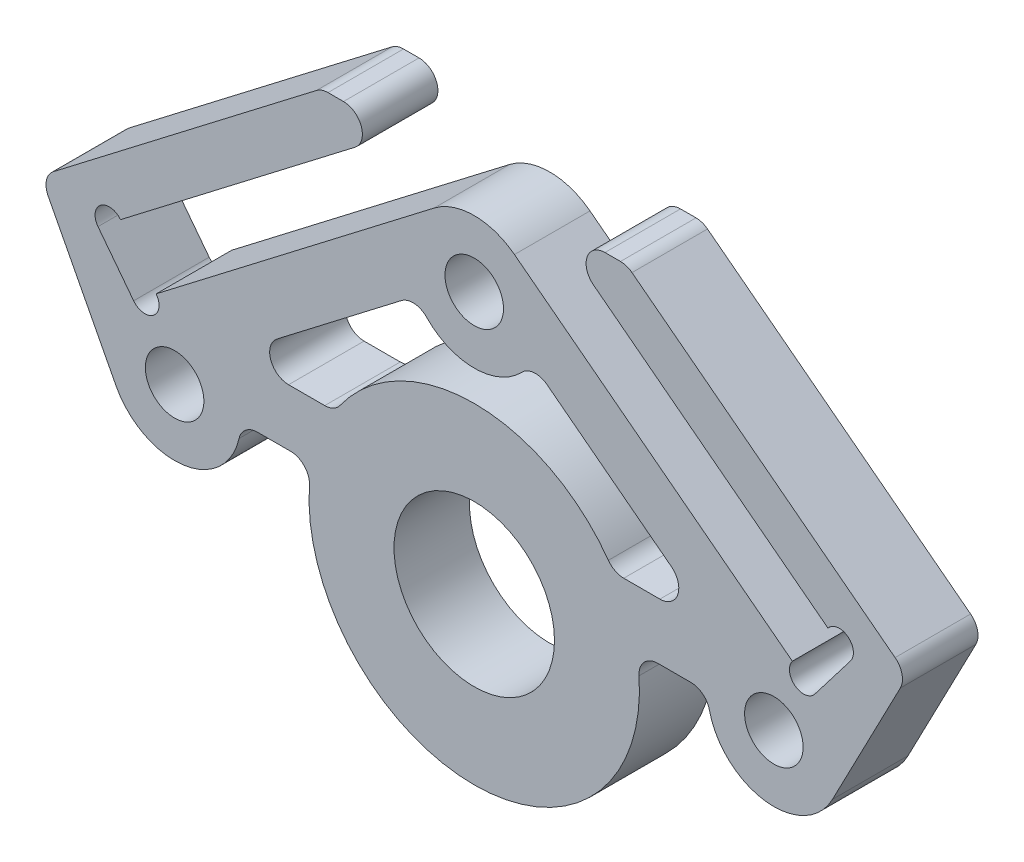
from build123d import *

# Parameters (mm, degrees)
SKETCH_1_R             = 4.25
SKETCH_1_R_2           = 1.55
EXTRUDE_1_DEPTH        = 2
FILLET_1_R             = 1
EXTRUDE_2_DEPTH        = 4
SKETCH_3_R             = 0.75
CUT_EXTRUDE_1_DEPTH    = 5
FILLET_2_R             = 1
FILLET_2_OF_MIRROR_1_R = 1
CUT_EXTRUDE_2_DEPTH    = 5
FILLET_3_R             = 1


with BuildPart() as part:
    # 草图1 → 凸台-拉伸1 (new body, symmetric)
    with BuildSketch(Plane.XY):
        with BuildLine():
            Line((-17.997731807, 4.466704665), (-2.130665002, 16.641933245))
            ThreePointArc((-2.130665002, 16.641933245), (0, 17.365196554), (2.130665002, 16.641933245))
            Line((2.130665002, 16.641933245), (17.997731807, 4.466704665))
            ThreePointArc((17.997731807, 4.466704665), (17.415077222, -1.449086621), (12.367066806, 1.689967974))
            Line((12.367066806, 1.689967974), (8.585249457, 1.689967974))
            ThreePointArc((8.585249457, 1.689967974), (0, -8.75), (-8.585249457, 1.689967974))
            Line((-8.585249457, 1.689967974), (-12.367066806, 1.689967974))
            ThreePointArc((-12.367066806, 1.689967974), (-17.415077222, -1.449086621), (-17.997731807, 4.466704665))
        make_face()
        Circle(SKETCH_1_R, mode=Mode.SUBTRACT)
        with Locations((-15.867066806, 1.689967974)):
            Circle(SKETCH_1_R_2, mode=Mode.SUBTRACT)
        with Locations((0, 13.865196554)):
            Circle(SKETCH_1_R_2, mode=Mode.SUBTRACT)
        with Locations((15.867066806, 1.689967974)):
            Circle(SKETCH_1_R_2, mode=Mode.SUBTRACT)
    extrude(amount=EXTRUDE_1_DEPTH, both=True)

    # 圆角1
    fillet_1_edges = [part.edges().sort_by_distance(p)[0] for p in [
        (12.367066806, 1.689967974, 0),
        (8.585249457, 1.689967974, 0),
        (-8.585249457, 1.689967974, 0),
        (-12.367066806, 1.689967974, 0),
    ]]
    fillet(fillet_1_edges, radius=FILLET_1_R)

    # 草图2 → 凸台-拉伸2 (add)
    with BuildSketch(Plane.XY.offset(2)):
        with BuildLine():
            Line((-18.971604722, 0.073847828), (-22.953372788, 7.722753116))
            Line((-22.953372788, 7.722753116), (-8.084856844, 19.131766671))
            Line((-8.084856844, 19.131766671), (-3.978157764, 19.131766671))
            Line((-3.978157764, 19.131766671), (-19.924559904, 6.895661948))
            Line((-19.924559904, 6.895661948), (-18.037399474, 4.436266594))
            Line((-18.037399474, 4.436266594), (-17.997731807, 4.466704665))
            ThreePointArc((-17.997731807, 4.466704665), (-19.284102831, 2.447506623), (-18.971604722, 0.073847828))
        make_face()
    extrude_2 = extrude(amount=-EXTRUDE_2_DEPTH)

    # 草图3 → 切除-拉伸1 (cut, through all)
    with BuildSketch(Plane.XY.offset(2)):
        with Locations((-19.329544899, 7.35223302)):
            Circle(SKETCH_3_R)
        with Locations((-17.442384469, 4.892837665)):
            Circle(SKETCH_3_R)
    cut_extrude_1 = extrude(amount=-CUT_EXTRUDE_1_DEPTH, mode=Mode.SUBTRACT)

    # 圆角2
    fillet_2_edges = [part.edges().sort_by_distance(p)[0] for p in [
        (-22.953372788, 7.722753116, 0),
        (-8.084856844, 19.131766671, 0),
        (-3.978157764, 19.131766671, 0),
    ]]
    fillet(fillet_2_edges, radius=FILLET_2_R)

    # 镜向1: 凸台-拉伸2, 切除-拉伸1 across plane
    add(extrude_2.mirror(Plane(origin=(0, 0, 0), x_dir=(0, 0, 1), z_dir=(1, 0, 0))))
    add(cut_extrude_1.mirror(Plane(origin=(0, 0, 0), x_dir=(0, 0, 1), z_dir=(1, 0, 0))), mode=Mode.SUBTRACT)

    # 圆角2 of 镜向1
    fillet_2_of_mirror_1_edges = [part.edges().sort_by_distance(p)[0] for p in [
        (22.953372788, 7.722753116, 0),
        (8.084856844, 19.131766671, 0),
        (3.978157764, 19.131766671, 0),
    ]]
    fillet(fillet_2_of_mirror_1_edges, radius=FILLET_2_OF_MIRROR_1_R)

    # 草图4 → 切除-拉伸2 (cut, through all)
    with BuildSketch(Plane.XY.offset(2)):
        with BuildLine():
            Line((-12.778730503, 4.689967974), (-3.052637302, 12.153061775))
            ThreePointArc((-3.052637302, 12.153061775), (0, 10.365196554), (3.052637302, 12.153061775))
            Line((3.052637302, 12.153061775), (12.778730503, 4.689967974))
            Line((12.778730503, 4.689967974), (7.38692767, 4.689967974))
            ThreePointArc((7.38692767, 4.689967974), (0, 8.75), (-7.38692767, 4.689967974))
            Line((-7.38692767, 4.689967974), (-12.778730503, 4.689967974))
        make_face()
    extrude(amount=-CUT_EXTRUDE_2_DEPTH, mode=Mode.SUBTRACT)

    # 圆角3
    fillet_3_edges = [part.edges().sort_by_distance(p)[0] for p in [
        (-7.38692767, 4.689967974, 0),
        (-12.778730503, 4.689967974, 0),
        (-3.052637302, 12.153061775, 0),
        (3.052637302, 12.153061775, 0),
        (12.778730503, 4.689967974, 0),
        (7.38692767, 4.689967974, 0),
    ]]
    fillet(fillet_3_edges, radius=FILLET_3_R)


solid = part.part
